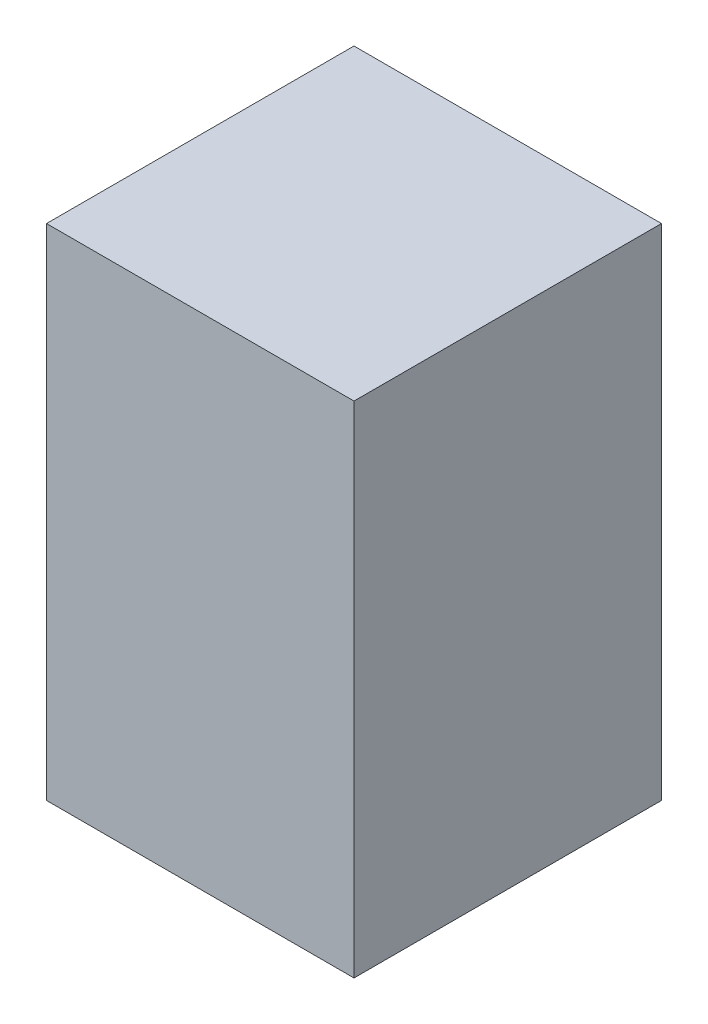
from build123d import *

# Parameters (mm, degrees)
SKETCH1_W           = 20
SKETCH1_H           = 20
BOSS_EXTRUDE1_DEPTH = 32.5


with BuildPart() as part:
    # Sketch1 → Boss-Extrude1 (new body)
    with BuildSketch(Plane(origin=(0, 0, 0), x_dir=(1, 0, 0), z_dir=(0, 1, 0))):
        Rectangle(SKETCH1_W, SKETCH1_H)
    extrude(amount=BOSS_EXTRUDE1_DEPTH)


solid = part.part
